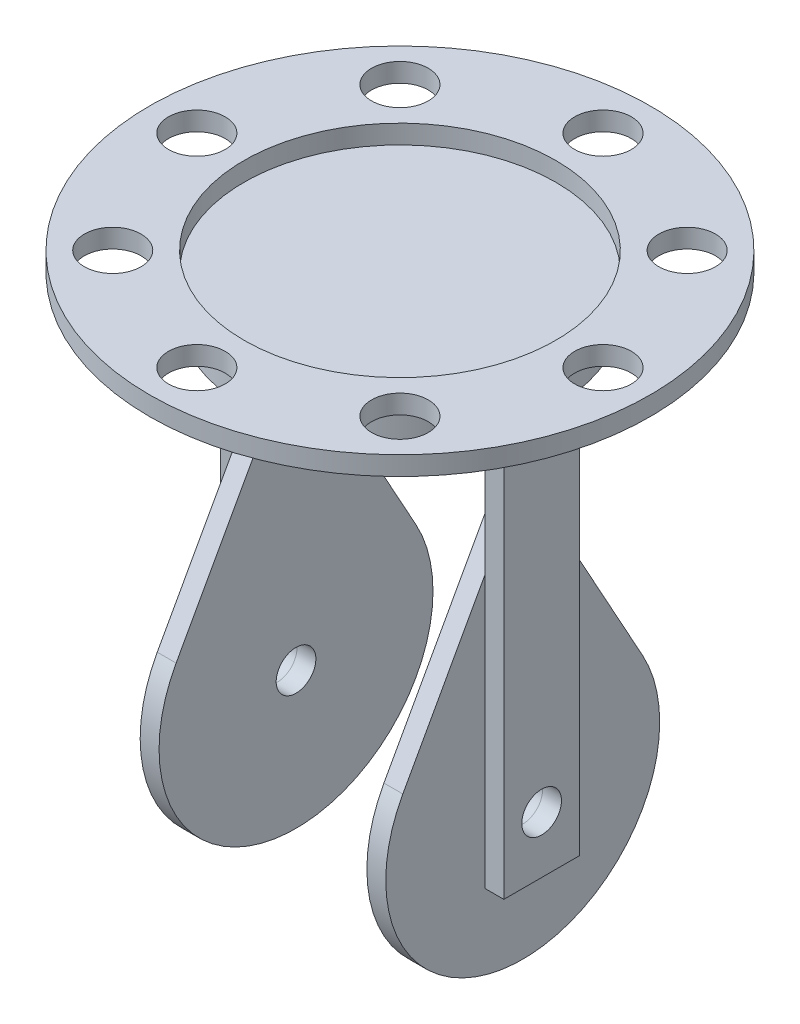
from build123d import *

# Parameters (mm, degrees)
SKETCH1_R           = 72.5
SKETCH1_R_2         = 10.5
BOSS_EXTRUDE1_DEPTH = 10
SKETCH2_W           = 40
SKETCH2_H           = 220
SKETCH2_R           = 10.5
BOSS_EXTRUDE2_DEPTH = 10
SKETCH3_W           = 40
SKETCH3_H           = 10
BOSS_EXTRUDE3_DEPTH = 65
FILLET1_R           = 10
FILLET2_R           = 20
SKETCH4_R           = 82.5
BOSS_EXTRUDE4_DEPTH = 20
SKETCH5_R           = 132.5
SKETCH5_R_2         = 82.5
BOSS_EXTRUDE5_DEPTH = 10
SKETCH6_R           = 15
CUT_EXTRUDE1_DEPTH  = 11


with BuildPart() as part:
    # Sketch1 → Boss-Extrude1 (new body)
    with BuildSketch(Plane(origin=(0, 0, 0), x_dir=(0, 0, -1), z_dir=(1, 0, 0))):
        with BuildLine():
            Line((-8.754363991, 134.143678161), (-63.469138936, 35.041666667))
            ThreePointArc((-63.469138936, 35.041666667), (0, 72.5), (63.469138936, 35.041666667))
            Line((63.469138936, 35.041666667), (8.754363991, 134.143678161))
            ThreePointArc((8.754363991, 134.143678161), (0, 139.310344828), (-8.754363991, 134.143678161))
        make_face()
        Circle(SKETCH1_R)
        Circle(SKETCH1_R_2, mode=Mode.SUBTRACT)
    extrude(amount=-BOSS_EXTRUDE1_DEPTH)


with BuildPart() as body_2:
    # Sketch2 → Boss-Extrude2 (new body)
    with BuildSketch(Plane(origin=(0, 0, 0), x_dir=(0, 0, -1), z_dir=(1, 0, 0))):
        with Locations((0, 80)):
            Rectangle(SKETCH2_W, SKETCH2_H)
        Circle(SKETCH2_R, mode=Mode.SUBTRACT)
    extrude(amount=BOSS_EXTRUDE2_DEPTH)

    # Sketch3 → Boss-Extrude3 (add)
    with BuildSketch(Plane.ZY):
        with Locations((0, 185)):
            Rectangle(SKETCH3_W, SKETCH3_H)
    extrude(amount=BOSS_EXTRUDE3_DEPTH)

    # Fillet1
    fillet1_edges = [body_2.edges().sort_by_distance(p)[0] for p in [
        (0, 180, 0),
    ]]
    fillet(fillet1_edges, radius=FILLET1_R)

    # Fillet2
    fillet2_edges = [body_2.edges().sort_by_distance(p)[0] for p in [
        (10, 190, 0),
    ]]
    fillet(fillet2_edges, radius=FILLET2_R)


with BuildPart() as body_3:
    # Mirror1: mirrored copy
    add(part.part.mirror(Plane.ZY.offset(65)))


with BuildPart() as body_4:
    # Mirror1 2: mirrored copy
    add(body_2.part.mirror(Plane.ZY.offset(65)))


with BuildPart() as body_5:
    # Sketch4 → Boss-Extrude4 (new body)
    with BuildSketch(Plane(origin=(0, 190, 0), x_dir=(1, 0, 0), z_dir=(0, 1, 0))):
        with Locations((-65, 0)):
            Circle(SKETCH4_R)
    extrude(amount=BOSS_EXTRUDE4_DEPTH)


with BuildPart() as body_6:
    # Sketch5 → Boss-Extrude5 (new body)
    with BuildSketch(Plane(origin=(0, 210, 0), x_dir=(1, 0, 0), z_dir=(0, 1, 0))):
        with Locations((-65, 0)):
            Circle(SKETCH5_R)
        with Locations((-65, 0)):
            Circle(SKETCH5_R_2, mode=Mode.SUBTRACT)
    extrude(amount=BOSS_EXTRUDE5_DEPTH)

    # Sketch6 → Cut-Extrude1 (cut, through all)
    with BuildSketch(Plane.XZ.offset(-210)):
        with Locations((-65, 107.5)):
            Circle(SKETCH6_R)
        with Locations((11.013978978, 76.013978978)):
            Circle(SKETCH6_R)
        with Locations((42.5, 0)):
            Circle(SKETCH6_R)
        with Locations((11.013978978, -76.013978978)):
            Circle(SKETCH6_R)
        with Locations((-65, -107.5)):
            Circle(SKETCH6_R)
        with Locations((-141.013978978, -76.013978978)):
            Circle(SKETCH6_R)
        with Locations((-172.5, 0)):
            Circle(SKETCH6_R)
        with Locations((-141.013978978, 76.013978978)):
            Circle(SKETCH6_R)
    extrude(amount=-CUT_EXTRUDE1_DEPTH, mode=Mode.SUBTRACT)


solid = Compound([part.part, body_2.part, body_3.part, body_4.part, body_5.part, body_6.part])
